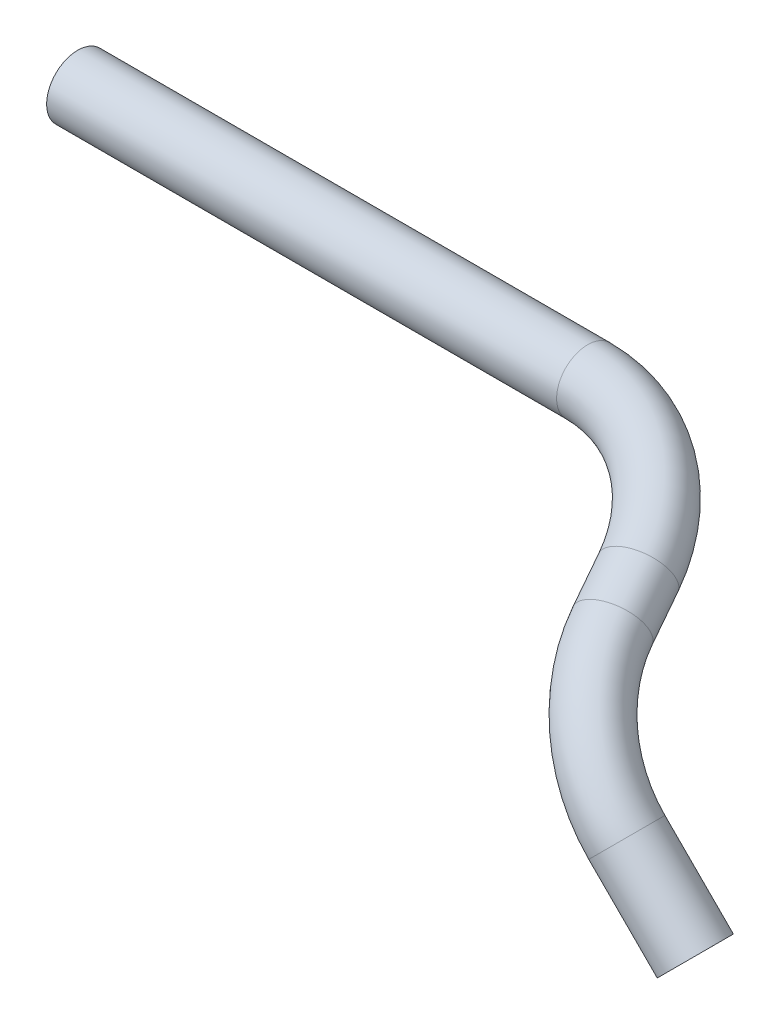
from build123d import *

# Parameters (mm, degrees)
SWEEP1_PROFILE_R = 12.7


with BuildPart() as part:
    # Sweep1: sweep along a curve in space
    with BuildLine() as sweep1_path:
        Line((0, 0, 0), (-27.957770282, 27.957770282, 0))
        ThreePointArc((-27.957770282, 27.957770282, 0), (-50.03467014, 50.782151029, -8.490952087), (-65.448601622, 68.238238275, -31.688664593))
        Line((-65.448601622, 68.238238275, -31.688664593), (-71.485347108, 75.730869643, -48.226689119))
        ThreePointArc((-71.485347108, 75.730869643, -48.226689119), (-94.593311277, 88.715779611, -76.887482501), (-131.741956946, 93.667995145, -87.818203358))
        Line((-131.741956946, 93.667995145, -87.818203358), (-339.937127276, 93.667995145, -87.818203358))
    # Sweep1 profile (on start of the path) → Sweep1 (sweep)
    with BuildSketch(Plane(origin=(0, 0, 0), x_dir=(0.707106781, 0.707106781, 0), z_dir=(-0.707106781, 0.707106781, 0))):
        Circle(SWEEP1_PROFILE_R)
    sweep(path=sweep1_path.line)


solid = part.part
